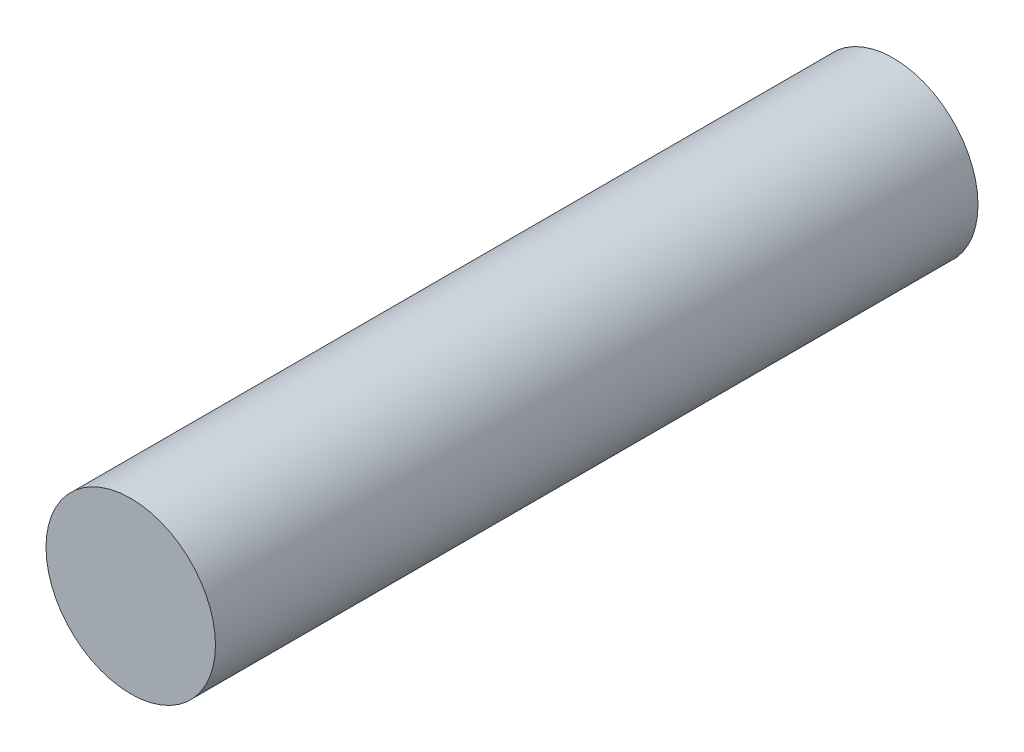
from build123d import *

# Parameters (mm, degrees)
SKETCH1_R           = 3.175
BOSS_EXTRUDE1_DEPTH = 14.2875


with BuildPart() as part:
    # Sketch1 → Boss-Extrude1 (new body, symmetric)
    with BuildSketch(Plane.XY):
        Circle(SKETCH1_R)
    extrude(amount=BOSS_EXTRUDE1_DEPTH, both=True)


solid = part.part
